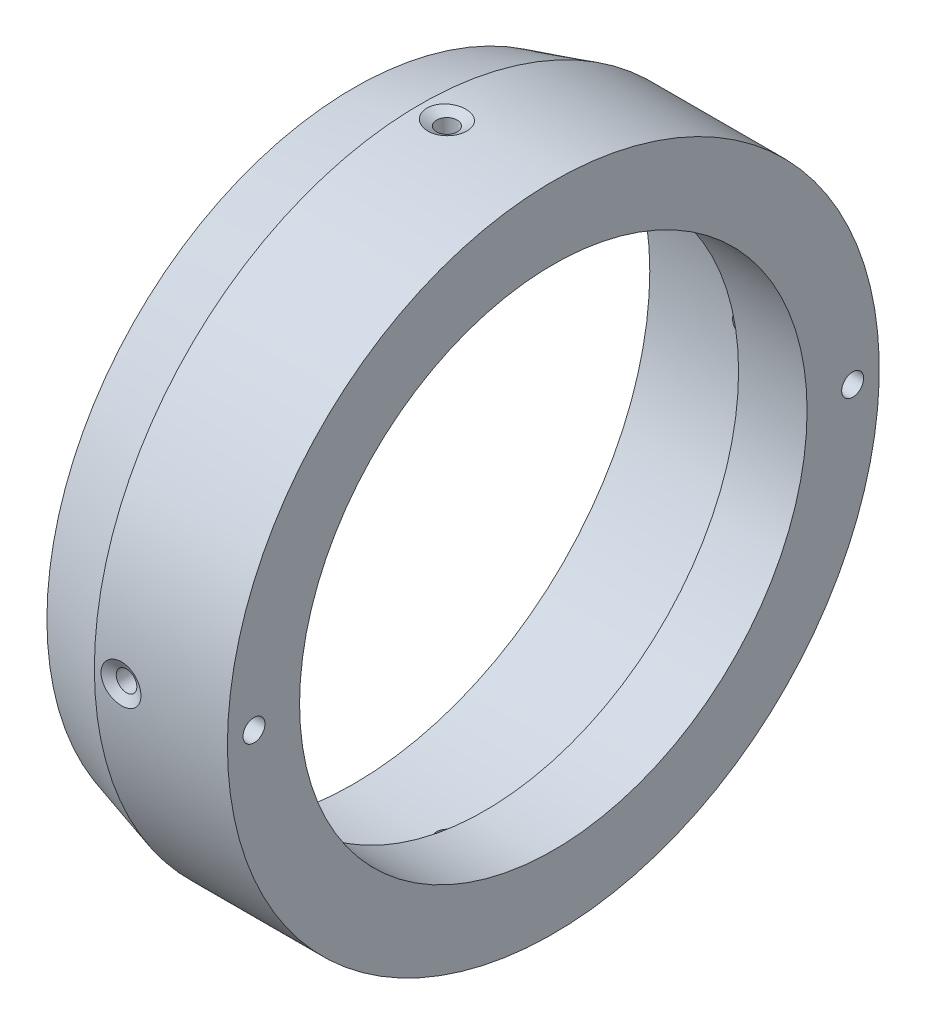
from build123d import *

# Parameters (mm, degrees)
CHANFREIN1_SIZE              = 10
CHANFREIN1_SIZE2             = 2.867453858
R_P_TITION_CIRCULAIRE1_COUNT = 2
R_P_TITION_CIRCULAIRE2_COUNT = 4


with BuildPart() as part:
    # Esquisse1 → Révolution1 (revolve)
    with BuildSketch(Plane.XY):
        Polygon((0, 49), (0, 38.15), (-10.3, 38.15), (-10.3, 44.5), (-30, 44.5), (-30, 49), align=None)
    revolve(axis=Axis((-37.547636856, 0, 0), (1, 0, 0)))

    # Chanfrein1
    chanfrein1_edges = [part.edges().sort_by_distance(p)[0] for p in [
        (-30, -49, 0),
    ]]
    chanfrein1_side = [part.faces().sort_by_distance(p)[0] for p in [
        (-15, -49, 0),
    ]]
    chamfer(chanfrein1_edges, length=CHANFREIN1_SIZE, length2=CHANFREIN1_SIZE2, reference=chanfrein1_side[0])

    # Esquisse6 → Trou taraudé M41 (revolve, cut)
    with BuildSketch(Plane(origin=(0, 0, -45), x_dir=(0, 0, -1), z_dir=(0, 1, 0))):
        Polygon((0, 0), (0, 7.991420021), (1.65, 7), (1.65, 0), align=None)
    trou_taraud_m41 = revolve(axis=Axis((6.35, 0, -45), (-1, 0, 0)), mode=Mode.SUBTRACT)

    # Répétition circulaire1: Trou taraudé M41 ×2 about axis
    r_p_tition_circulaire1_axis = Axis((0, 0, 0), (1, 0, 0))
    for i in range(1, R_P_TITION_CIRCULAIRE1_COUNT):
        add(trou_taraud_m41.rotate(r_p_tition_circulaire1_axis, i * 360 / R_P_TITION_CIRCULAIRE1_COUNT), mode=Mode.SUBTRACT)

    # Esquisse8 → Dégagement M2.51 (revolve, cut)
    with BuildSketch(Plane(origin=(-16, 0, -49), x_dir=(0, 1, 0), z_dir=(1, 0, 0))):
        Polygon((0, 0), (0, 20.931333959), (1.55, 20), (1.55, 0.83715789), (3, 0), align=None)
    d_gagement_m2_51 = revolve(axis=Axis((-16, 0, -55.35), (0, 0, 1)), mode=Mode.SUBTRACT)

    # Répétition circulaire2: Dégagement M2.51 ×4 about axis
    r_p_tition_circulaire2_axis = Axis((0, 0, 0), (-1, 0, 0))
    for i in range(1, R_P_TITION_CIRCULAIRE2_COUNT):
        add(d_gagement_m2_51.rotate(r_p_tition_circulaire2_axis, i * 360 / R_P_TITION_CIRCULAIRE2_COUNT), mode=Mode.SUBTRACT)


solid = part.part
